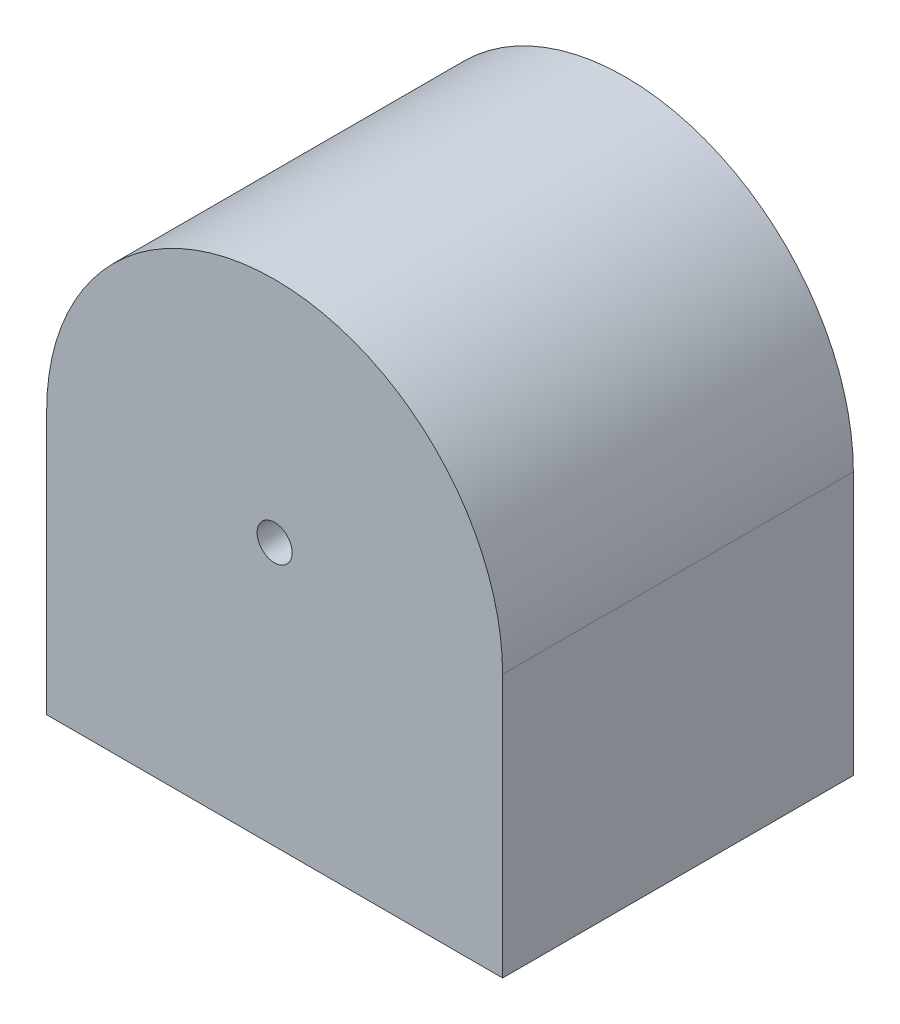
from build123d import *

# Parameters (mm, degrees)
SALIENTE_EXTRUIR1_DEPTH = 100
VACIADO1_T              = -10
CROQUIS4_R              = 5
CORTAR_EXTRUIR1_DEPTH   = 130


with BuildPart() as part:
    # Croquis1 → Saliente-Extruir1 (new body)
    with BuildSketch(Plane.XY):
        with BuildLine():
            Line((-65, 0), (-65, -65))
            Line((-65, -65), (-65, -75))
            Line((-65, -75), (0, -75))
            Line((0, -75), (65, -75))
            Line((65, -75), (65, -65))
            Line((65, -65), (65, 0))
            ThreePointArc((65, 0), (0, 65), (-65, 0))
        make_face()
    extrude(amount=SALIENTE_EXTRUIR1_DEPTH)

    # Vaciado1
    vaciado1_openings = [part.faces().sort_by_distance(p)[0] for p in [
        (0, -75, 50),
    ]]
    offset(amount=VACIADO1_T, openings=vaciado1_openings, kind=Kind.INTERSECTION)

    # Croquis4 → Cortar-Extruir1 (cut)
    with BuildSketch(Plane.XY.offset(100)):
        Circle(CROQUIS4_R)
    extrude(amount=-CORTAR_EXTRUIR1_DEPTH, mode=Mode.SUBTRACT)


solid = part.part
